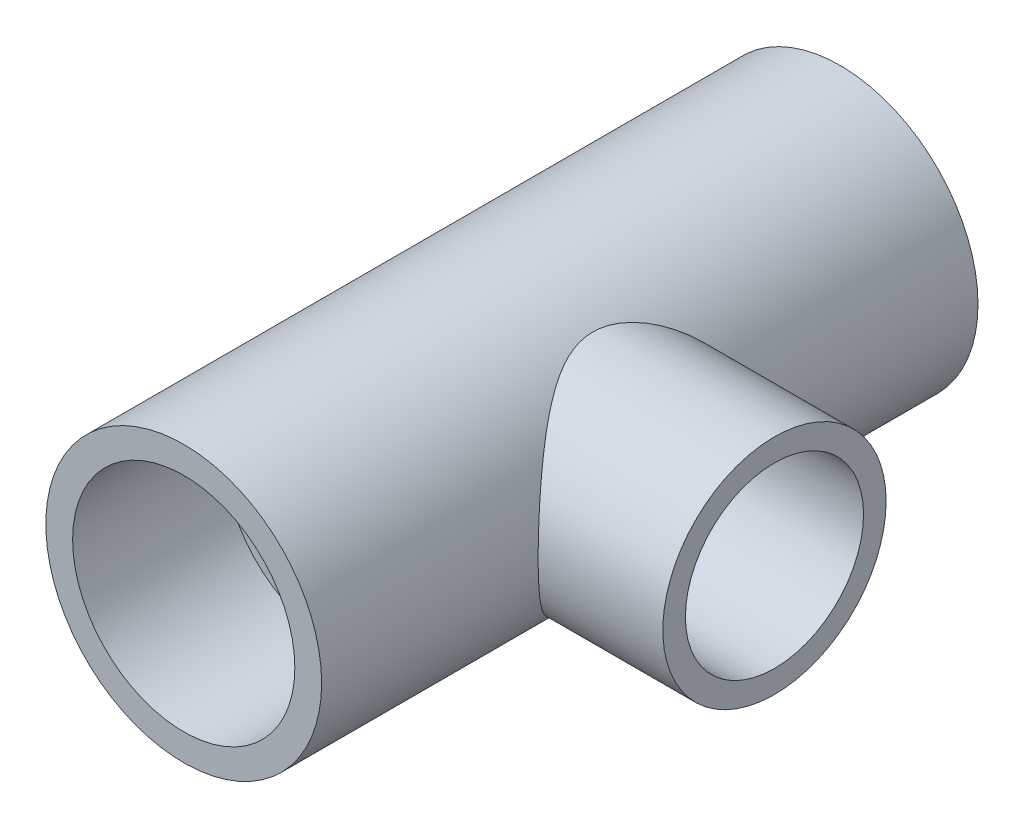
from build123d import *

# Parameters (mm, degrees)
SKETCH1_R           = 656.5
SKETCH1_R_2         = 412
BOSS_EXTRUDE1_DEPTH = 3125
SKETCH2_R           = 529
CUT_EXTRUDE1_DEPTH  = 720
SKETCH3_R           = 529
CUT_EXTRUDE2_DEPTH  = 720
SKETCH7_R           = 531.5
SKETCH7_R_2         = 311
BOSS_EXTRUDE3_DEPTH = 1250
SKETCH8_R           = 311
CUT_EXTRUDE7_DEPTH  = 1250
SKETCH10_R          = 424
CUT_EXTRUDE8_DEPTH  = 690


with BuildPart() as part:
    # Sketch1 → Boss-Extrude1 (new body)
    with BuildSketch(Plane.XY):
        Circle(SKETCH1_R)
        Circle(SKETCH1_R_2, mode=Mode.SUBTRACT)
    extrude(amount=BOSS_EXTRUDE1_DEPTH)

    # Sketch2 → Cut-Extrude1 (cut)
    with BuildSketch(Plane.XY.offset(3125)):
        Circle(SKETCH2_R)
    extrude(amount=-CUT_EXTRUDE1_DEPTH, mode=Mode.SUBTRACT)

    # Sketch3 → Cut-Extrude2 (cut)
    with BuildSketch(Plane(origin=(0, 0, 0), x_dir=(-1, 0, 0), z_dir=(0, 0, -1))):
        Circle(SKETCH3_R)
    extrude(amount=-CUT_EXTRUDE2_DEPTH, mode=Mode.SUBTRACT)

    # Sketch7 → Boss-Extrude3 (add)
    with BuildSketch(Plane(origin=(0, 0, 0), x_dir=(0, 0, -1), z_dir=(1, 0, 0))):
        with Locations((-1562.5, 0)):
            Circle(SKETCH7_R)
        with Locations((-1562.5, 0)):
            Circle(SKETCH7_R_2, mode=Mode.SUBTRACT)
    extrude(amount=BOSS_EXTRUDE3_DEPTH)

    # Sketch8 → Cut-Extrude7 (cut)
    with BuildSketch(Plane(origin=(0, 0, 0), x_dir=(0, 0, -1), z_dir=(1, 0, 0))):
        with Locations((-1562.5, 0)):
            Circle(SKETCH8_R)
    extrude(amount=CUT_EXTRUDE7_DEPTH, mode=Mode.SUBTRACT)

    # Sketch10 → Cut-Extrude8 (cut)
    with BuildSketch(Plane(origin=(1250, 0, 0), x_dir=(0, 0, -1), z_dir=(1, 0, 0))):
        with Locations((-1562.5, 0)):
            Circle(SKETCH10_R)
    extrude(amount=-CUT_EXTRUDE8_DEPTH, mode=Mode.SUBTRACT)


solid = part.part
